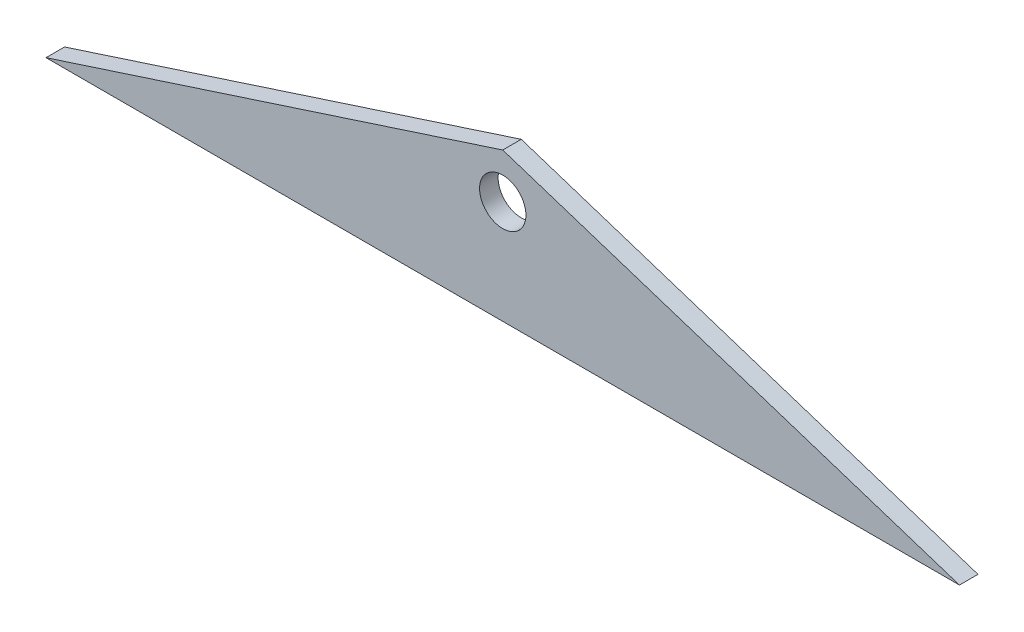
from build123d import *

# Parameters (mm, degrees)
EXTRUDE1_DEPTH     = 3.175
CUT_EXTRUDE1_REACH = 5.175
SKETCH2_R          = 3.96875


with BuildPart() as part:
    # Sketch1 → Extrude1 (new body)
    with BuildSketch(Plane.XY):
        Polygon((78.173161844, -379.67231274), (0, -354.27231274), (-78.173161844, -379.67231274), align=None)
    extrude(amount=EXTRUDE1_DEPTH)

    # Sketch2 → Cut-Extrude1 (cut, up to next)
    with BuildSketch(Plane.XY.offset(3.175), mode=Mode.PRIVATE) as cut_extrude1_sk1:
        with Locations((0, -361.95)):
            Circle(SKETCH2_R)
    cut_extrude1_tool1 = extrude(cut_extrude1_sk1.sketch, amount=-CUT_EXTRUDE1_REACH, mode=Mode.PRIVATE) & part.part
    add(cut_extrude1_tool1.solids().sort_by_distance((0, -361.95, 3.175))[0], mode=Mode.SUBTRACT)


solid = part.part
